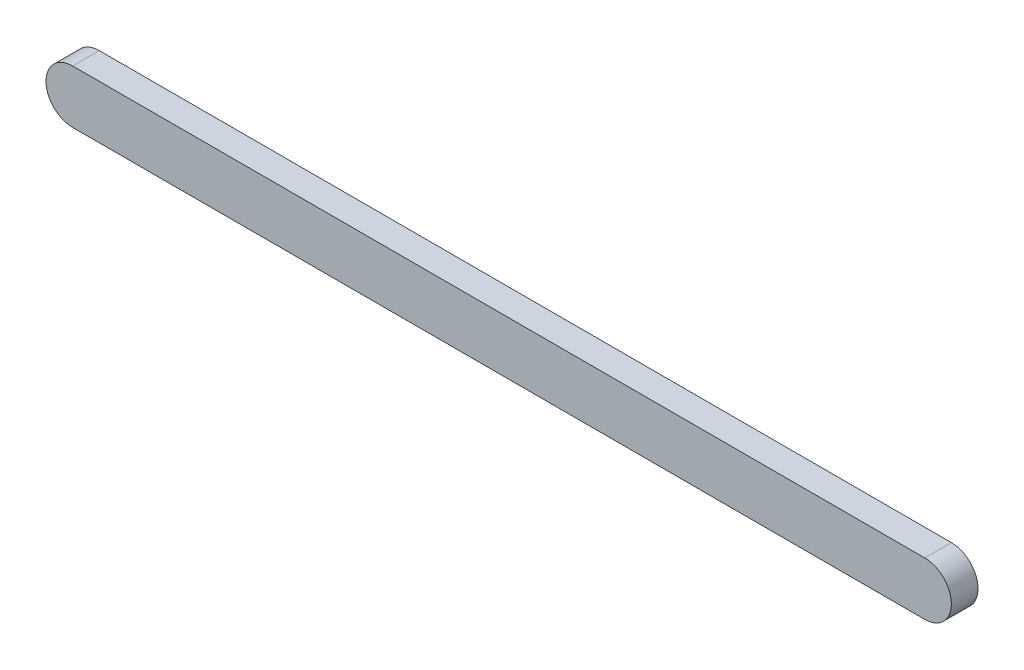
from build123d import *

# Parameters (mm, degrees)
BOSS_EXTRUDE1_DEPTH = 2.5


with BuildPart() as part:
    # Sketch1 → Boss-Extrude1 (new body)
    with BuildSketch(Plane.XY):
        with BuildLine():
            Line((0, 2.5), (80, 2.5))
            ThreePointArc((80, 2.5), (82.5, 0), (80, -2.5))
            Line((80, -2.5), (0, -2.5))
            ThreePointArc((0, -2.5), (-2.5, 0), (0, 2.5))
        make_face()
    extrude(amount=BOSS_EXTRUDE1_DEPTH)


solid = part.part
